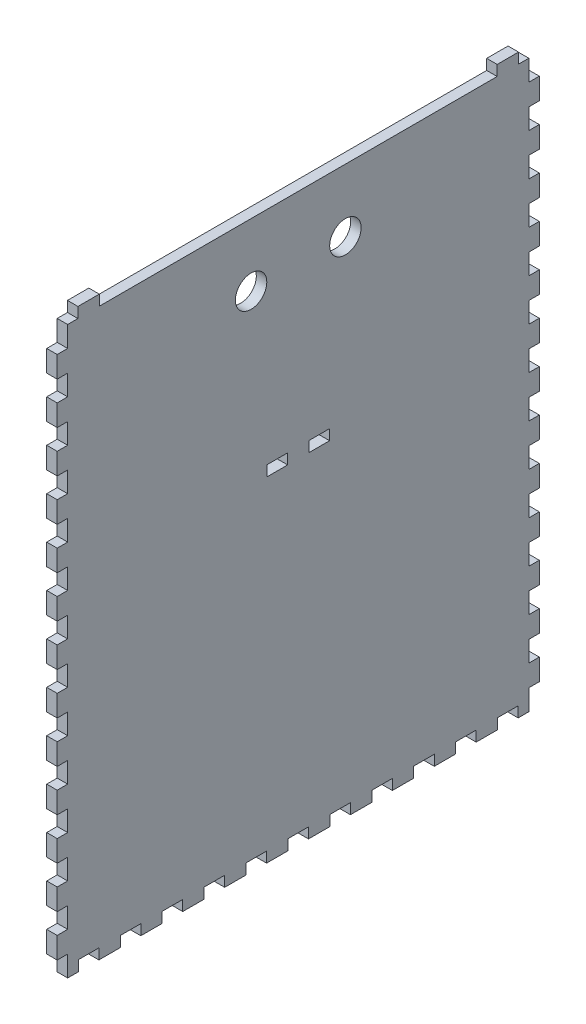
from build123d import *

# Parameters (mm, degrees)
SKETCH1_R           = 9.525
SKETCH1_W           = 12.573
SKETCH1_H           = 6.35
BOSS_EXTRUDE1_DEPTH = 6.35


with BuildPart() as part:
    # Sketch1 → Boss-Extrude1 (new body)
    with BuildSketch(Plane(origin=(0, 0, 0), x_dir=(0, 0, -1), z_dir=(1, 0, 0))):
        Polygon((0, 0), (6.223, 0), (6.223, 6.35), (19.177, 6.35), (19.177, 0), (260.223, 0), (260.223, 6.35), (273.177, 6.35), (273.177, 0), (279.4, 0), (279.4, -12.573), (285.75, -12.573), (285.75, -25.527), (279.4, -25.527), (279.4, -37.973), (285.75, -37.973), (285.75, -50.927), (279.4, -50.927), (279.4, -63.373), (285.75, -63.373), (285.75, -76.327), (279.4, -76.327), (279.4, -88.773), (285.75, -88.773), (285.75, -101.727), (279.4, -101.727), (279.4, -114.173), (285.75, -114.173), (285.75, -127.127), (279.4, -127.127), (279.4, -139.573), (285.75, -139.573), (285.75, -152.527), (279.4, -152.527), (279.4, -164.973), (285.75, -164.973), (285.75, -177.927), (279.4, -177.927), (279.4, -190.373), (285.75, -190.373), (285.75, -203.327), (279.4, -203.327), (279.4, -215.773), (285.75, -215.773), (285.75, -228.727), (279.4, -228.727), (279.4, -241.173), (285.75, -241.173), (285.75, -254.127), (279.4, -254.127), (279.4, -266.573), (285.75, -266.573), (285.75, -279.527), (279.4, -279.527), (279.4, -291.973), (285.75, -291.973), (285.75, -304.927), (279.4, -304.927), (279.4, -317.373), (285.75, -317.373), (285.75, -330.327), (279.4, -330.327), (279.4, -342.9), (272.923, -342.9), (272.923, -336.55), (260.477, -336.55), (260.477, -342.9), (247.523, -342.9), (247.523, -336.55), (235.077, -336.55), (235.077, -342.9), (222.123, -342.9), (222.123, -336.55), (209.677, -336.55), (209.677, -342.9), (196.723, -342.9), (196.723, -336.55), (184.277, -336.55), (184.277, -342.9), (171.323, -342.9), (171.323, -336.55), (158.877, -336.55), (158.877, -342.9), (145.923, -342.9), (145.923, -336.55), (133.477, -336.55), (133.477, -342.9), (120.523, -342.9), (120.523, -336.55), (108.077, -336.55), (108.077, -342.9), (95.123, -342.9), (95.123, -336.55), (82.677, -336.55), (82.677, -342.9), (69.723, -342.9), (69.723, -336.55), (57.277, -336.55), (57.277, -342.9), (44.323, -342.9), (44.323, -336.55), (31.877, -336.55), (31.877, -342.9), (18.923, -342.9), (18.923, -336.55), (6.477, -336.55), (6.477, -342.9), (0, -342.9), (0, -330.327), (-6.35, -330.327), (-6.35, -317.373), (0, -317.373), (0, -304.927), (-6.35, -304.927), (-6.35, -291.973), (0, -291.973), (0, -279.527), (-6.35, -279.527), (-6.35, -266.573), (0, -266.573), (0, -254.127), (-6.35, -254.127), (-6.35, -241.173), (0, -241.173), (0, -228.727), (-6.35, -228.727), (-6.35, -215.773), (0, -215.773), (0, -203.327), (-6.35, -203.327), (-6.35, -190.373), (0, -190.373), (0, -177.927), (-6.35, -177.927), (-6.35, -164.973), (0, -164.973), (0, -152.527), (-6.35, -152.527), (-6.35, -139.573), (0, -139.573), (0, -127.127), (-6.35, -127.127), (-6.35, -114.173), (0, -114.173), (0, -101.727), (-6.35, -101.727), (-6.35, -88.773), (0, -88.773), (0, -76.327), (-6.35, -76.327), (-6.35, -63.373), (0, -63.373), (0, -50.927), (-6.35, -50.927), (-6.35, -37.973), (0, -37.973), (0, -25.527), (-6.35, -25.527), (-6.35, -12.573), (0, -12.573), align=None)
        with Locations((111.125, -38.1)):
            Circle(SKETCH1_R, mode=Mode.SUBTRACT)
        with Locations((168.275, -38.1)):
            Circle(SKETCH1_R, mode=Mode.SUBTRACT)
        with Locations((127, -137.16)):
            Rectangle(SKETCH1_W, SKETCH1_H, mode=Mode.SUBTRACT)
        with Locations((152.4, -137.16)):
            Rectangle(SKETCH1_W, SKETCH1_H, mode=Mode.SUBTRACT)
    extrude(amount=BOSS_EXTRUDE1_DEPTH)


solid = part.part
